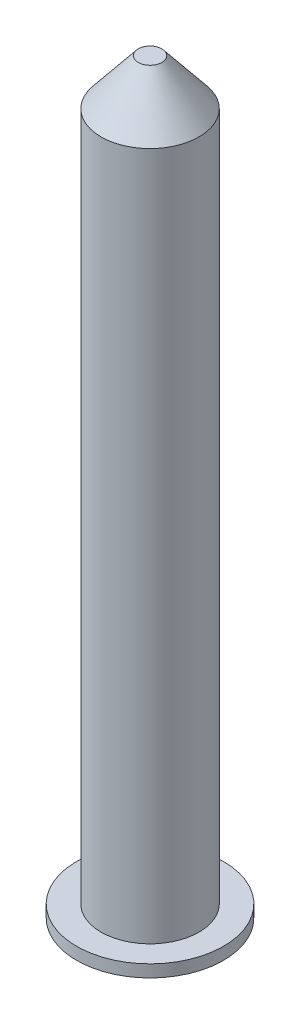
from build123d import *

# Parameters (mm, degrees)
SKETCH2_R           = 2.54
BOSS_EXTRUDE1_DEPTH = 38.1
CHAMFER1_SIZE       = 2.38
CHAMFER1_SIZE2      = 1.927285999
SKETCH3_R           = 3.81
BOSS_EXTRUDE2_DEPTH = 0.635


with BuildPart() as part:
    # Sketch2 → Boss-Extrude1 (new body)
    with BuildSketch(Plane(origin=(0, 0, 0), x_dir=(1, 0, 0), z_dir=(0, 1, 0))):
        Circle(SKETCH2_R)
    extrude(amount=BOSS_EXTRUDE1_DEPTH)

    # Chamfer1
    chamfer1_edges = [part.edges().sort_by_distance(p)[0] for p in [
        (-2.54, 38.1, 0),
    ]]
    chamfer1_side = [part.faces().sort_by_distance(p)[0] for p in [
        (-2.54, 19.05, 0),
    ]]
    chamfer(chamfer1_edges, length=CHAMFER1_SIZE, length2=CHAMFER1_SIZE2, reference=chamfer1_side[0])

    # Sketch3 → Boss-Extrude2 (add)
    with BuildSketch(Plane(origin=(0, 0, 0), x_dir=(-1, 0, 0), z_dir=(0, -1, 0))):
        Circle(SKETCH3_R)
    extrude(amount=BOSS_EXTRUDE2_DEPTH)


solid = part.part
